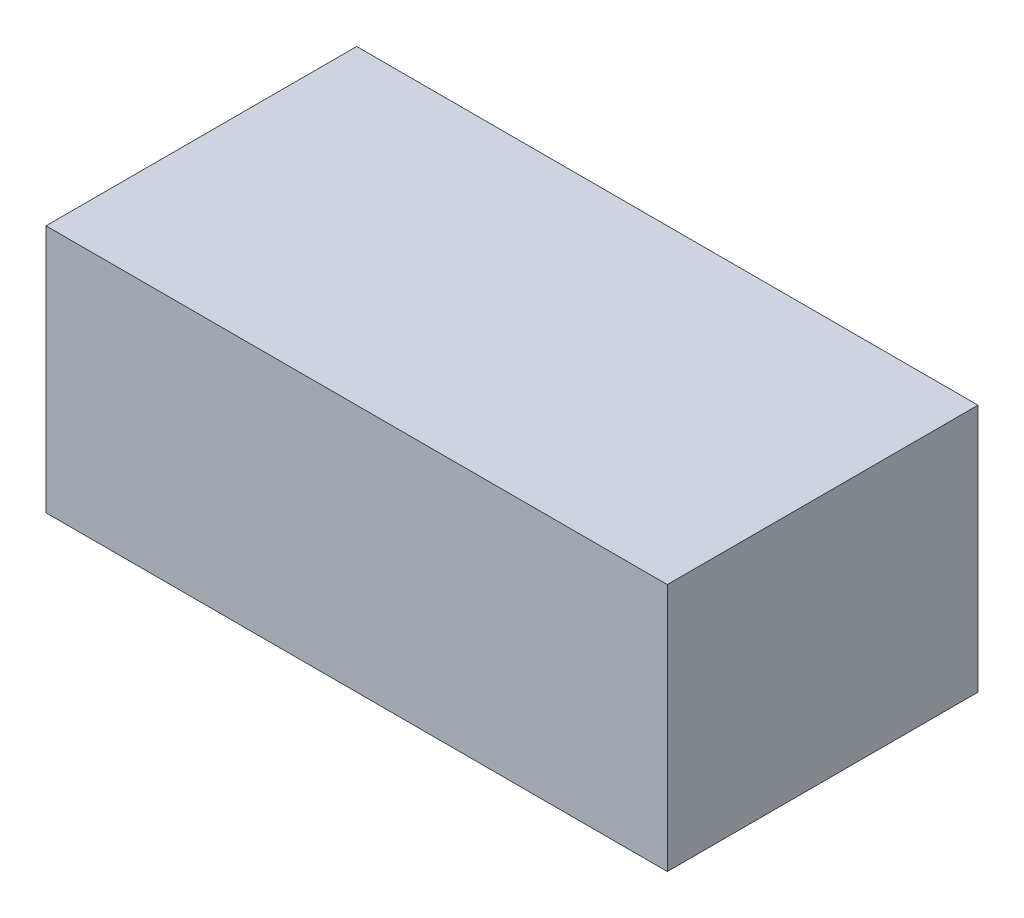
from build123d import *

# Parameters (mm, degrees)
SKETCH1_W           = 20
SKETCH1_H           = 10
BOSS_EXTRUDE1_DEPTH = 8


with BuildPart() as part:
    # Sketch1 → Boss-Extrude1 (new body)
    with BuildSketch(Plane(origin=(0, 0, 0), x_dir=(1, 0, 0), z_dir=(0, 1, 0))):
        with Locations((10, 5)):
            Rectangle(SKETCH1_W, SKETCH1_H)
    extrude(amount=BOSS_EXTRUDE1_DEPTH)


solid = part.part
